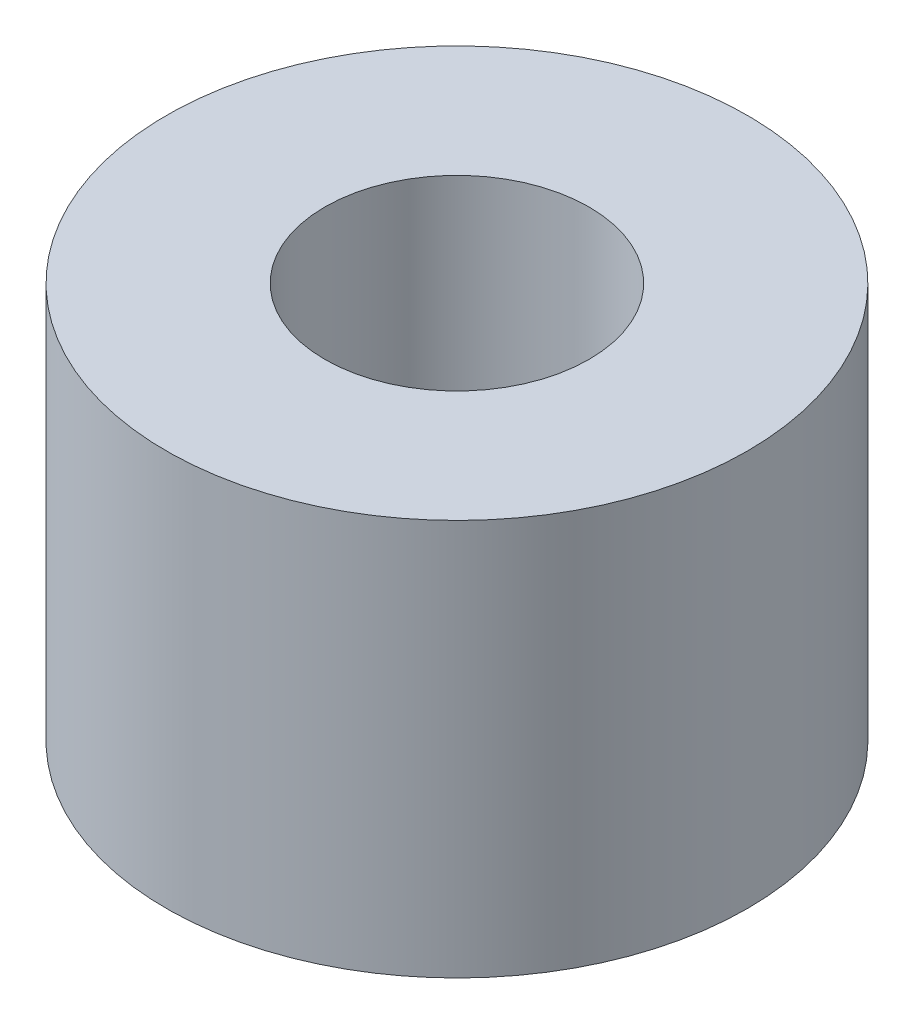
from build123d import *

# Parameters (mm, degrees)
SKETCH1_W         = 2.2
SKETCH1_H         = 3
SKETCH2_R         = 1
TENDON_HOLE_DEPTH = 3


with BuildPart() as part:
    # Sketch1 → main body (revolve)
    with BuildSketch(Plane.XY):
        with Locations((-1.1, 0)):
            Rectangle(SKETCH1_W, SKETCH1_H)
    revolve(axis=Axis((0, -1.5, 0), (0, 1, 0)))

    # Sketch2 → tendon hole (cut)
    with BuildSketch(Plane(origin=(0, 1.5, 0), x_dir=(1, 0, 0), z_dir=(0, 1, 0))):
        Circle(SKETCH2_R)
    extrude(amount=-TENDON_HOLE_DEPTH, mode=Mode.SUBTRACT)


solid = part.part
